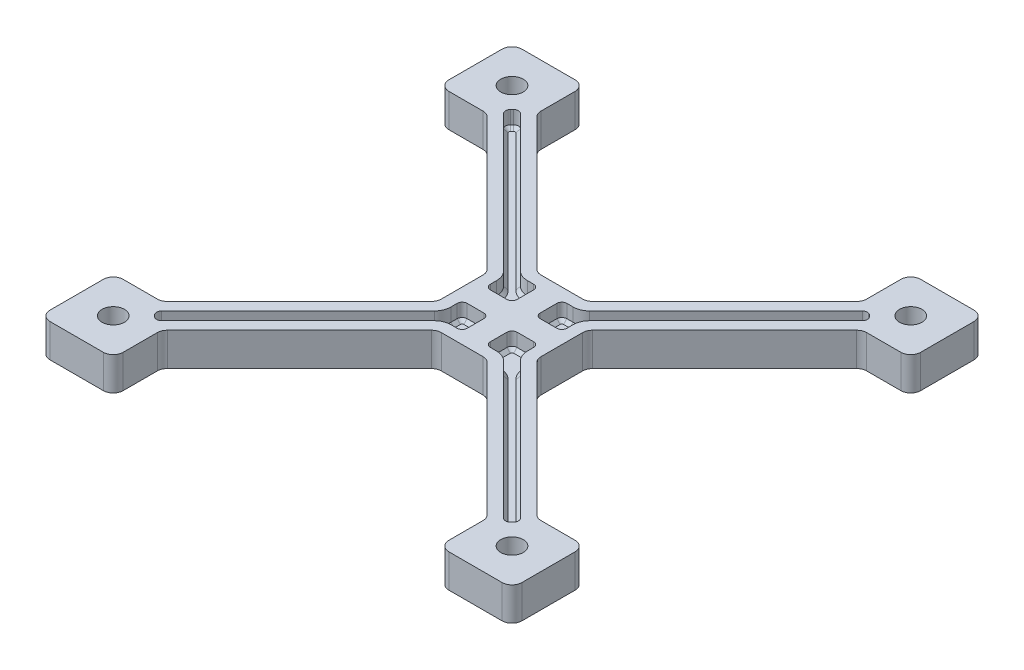
from build123d import *

# Parameters (mm, degrees)
SKETCH1_W               = 22
SKETCH1_H               = 22
BOSS_EXTRUDE1_DEPTH     = 10
F_1_4_CLEARANCE_HOLE1_D = 6.7564
CUT_EXTRUDE1_DEPTH      = 5
CHAMFER1_SIZE           = 1
FILLET1_R               = 3


with BuildPart() as part:
    # Sketch1 → Boss-Extrude1 (new body)
    with BuildSketch(Plane(origin=(0, 0, 0), x_dir=(1, 0, 0), z_dir=(0, 1, 0))):
        with Locations((15, 15)):
            Rectangle(SKETCH1_W, SKETCH1_H)
        Polygon((60, 60), (60, 67.5), (18.5, 26), (26, 26), (26, 18.5), (67.5, 60), align=None)
        Polygon((60, 75), (60, 90), (75, 90), (90, 90), (90, 60), (75, 60), (60, 60), align=None)
        Polygon((90, 60), (82.5, 60), (124, 18.5), (124, 26), (131.5, 26), (90, 67.5), align=None)
        with Locations((135, 15)):
            Rectangle(SKETCH1_W, SKETCH1_H)
        with Locations((135, 135)):
            Rectangle(SKETCH1_W, SKETCH1_H)
        Polygon((124, 131.5), (82.5, 90), (90, 90), (90, 82.5), (131.5, 124), (124, 124), align=None)
        Polygon((18.5, 124), (60, 82.5), (60, 90), (67.5, 90), (26, 131.5), (26, 124), align=None)
        with Locations((15, 135)):
            Rectangle(SKETCH1_W, SKETCH1_H)
    extrude(amount=-BOSS_EXTRUDE1_DEPTH)

    # 1/4 Clearance Hole1 (through all)
    with Locations(Plane(origin=(0, 0, 0), x_dir=(1, 0, 0), z_dir=(0, 1, 0))):
        with Locations((15, 15), (15, 135), (135, 135), (135, 15)):
            Hole(F_1_4_CLEARANCE_HOLE1_D / 2)

    # Sketch4 → Cut-Extrude1 (cut)
    with BuildSketch(Plane(origin=(0, 0, 0), x_dir=(1, 0, 0), z_dir=(0, 1, 0))):
        with BuildLine():
            Line((86.5, 70), (86.5, 68.121320344))
            ThreePointArc((86.5, 68.121320344), (86.880602337, 66.207903182), (87.964466094, 64.585786438))
            Line((87.964466094, 64.585786438), (128.98959236, 23.560660172))
            ThreePointArc((128.98959236, 23.560660172), (129.428932188, 22.5), (128.98959236, 21.439339828))
            Line((128.98959236, 21.439339828), (128.560660172, 21.01040764))
            ThreePointArc((128.560660172, 21.01040764), (127.5, 20.571067812), (126.439339828, 21.01040764))
            Line((126.439339828, 21.01040764), (85.414213562, 62.035533906))
            ThreePointArc((85.414213562, 62.035533906), (83.792096818, 63.119397663), (81.878679656, 63.5))
            Line((81.878679656, 63.5), (80, 63.5))
            ThreePointArc((80, 63.5), (78.939339828, 63.939339828), (78.5, 65))
            Line((78.5, 65), (78.5, 70))
            ThreePointArc((78.5, 70), (78.939339828, 71.060660172), (80, 71.5))
            Line((80, 71.5), (85, 71.5))
            ThreePointArc((85, 71.5), (86.060660172, 71.060660172), (86.5, 70))
        make_face()
        with BuildLine():
            Line((62.035533906, 64.585786438), (21.01040764, 23.560660172))
            ThreePointArc((21.01040764, 23.560660172), (20.571067812, 22.5), (21.01040764, 21.439339828))
            Line((21.01040764, 21.439339828), (21.439339828, 21.01040764))
            ThreePointArc((21.439339828, 21.01040764), (22.5, 20.571067812), (23.560660172, 21.01040764))
            Line((23.560660172, 21.01040764), (64.585786438, 62.035533906))
            ThreePointArc((64.585786438, 62.035533906), (66.207903182, 63.119397663), (68.121320344, 63.5))
            Line((68.121320344, 63.5), (70, 63.5))
            ThreePointArc((70, 63.5), (71.060660172, 63.939339828), (71.5, 65))
            Line((71.5, 65), (71.5, 70))
            ThreePointArc((71.5, 70), (71.060660172, 71.060660172), (70, 71.5))
            Line((70, 71.5), (65, 71.5))
            ThreePointArc((65, 71.5), (63.939339828, 71.060660172), (63.5, 70))
            Line((63.5, 70), (63.5, 68.121320344))
            ThreePointArc((63.5, 68.121320344), (63.119397663, 66.207903182), (62.035533906, 64.585786438))
        make_face()
        with BuildLine():
            Line((63.5, 80), (63.5, 81.878679656))
            ThreePointArc((63.5, 81.878679656), (63.119397663, 83.792096818), (62.035533906, 85.414213562))
            Line((62.035533906, 85.414213562), (21.01040764, 126.439339828))
            ThreePointArc((21.01040764, 126.439339828), (20.571067812, 127.5), (21.01040764, 128.560660172))
            Line((21.01040764, 128.560660172), (21.439339828, 128.98959236))
            ThreePointArc((21.439339828, 128.98959236), (22.5, 129.428932188), (23.560660172, 128.98959236))
            Line((23.560660172, 128.98959236), (64.585786438, 87.964466094))
            ThreePointArc((64.585786438, 87.964466094), (66.207903182, 86.880602337), (68.121320344, 86.5))
            Line((68.121320344, 86.5), (70, 86.5))
            ThreePointArc((70, 86.5), (71.060660172, 86.060660172), (71.5, 85))
            Line((71.5, 85), (71.5, 80))
            ThreePointArc((71.5, 80), (71.060660172, 78.939339828), (70, 78.5))
            Line((70, 78.5), (65, 78.5))
            ThreePointArc((65, 78.5), (63.939339828, 78.939339828), (63.5, 80))
        make_face()
        with BuildLine():
            Line((128.560660172, 128.98959236), (128.98959236, 128.560660172))
            ThreePointArc((128.98959236, 128.560660172), (129.428932188, 127.5), (128.98959236, 126.439339828))
            Line((128.98959236, 126.439339828), (87.964466094, 85.414213562))
            ThreePointArc((87.964466094, 85.414213562), (86.880602337, 83.792096818), (86.5, 81.878679656))
            Line((86.5, 81.878679656), (86.5, 80))
            ThreePointArc((86.5, 80), (86.060660172, 78.939339828), (85, 78.5))
            Line((85, 78.5), (80, 78.5))
            ThreePointArc((80, 78.5), (78.939339828, 78.939339828), (78.5, 80))
            Line((78.5, 80), (78.5, 85))
            ThreePointArc((78.5, 85), (78.939339828, 86.060660172), (80, 86.5))
            Line((80, 86.5), (81.878679656, 86.5))
            ThreePointArc((81.878679656, 86.5), (83.792096818, 86.880602337), (85.414213562, 87.964466094))
            Line((85.414213562, 87.964466094), (126.439339828, 128.98959236))
            ThreePointArc((126.439339828, 128.98959236), (127.5, 129.428932188), (128.560660172, 128.98959236))
        make_face()
    extrude(amount=-CUT_EXTRUDE1_DEPTH, mode=Mode.SUBTRACT)

    # Chamfer1
    chamfer1_edges = [part.edges().sort_by_distance(p)[0] for p in [
        (18.3782, -10, -135),
        (18.3782, -10, -15),
        (63.119397663, -5, -83.792096818),
        (41.522970773, -5, -105.926776695),
        (20.571067812, -5, -127.5),
        (21.224873734, -5, -128.775126266),
        (22.5, -5, -129.428932188),
        (44.073223305, -5, -108.477029227),
        (66.207903182, -5, -86.880602337),
        (69.060660172, -5, -86.5),
        (71.060660172, -5, -86.060660172),
        (71.5, -5, -82.5),
        (71.060660172, -5, -78.939339828),
        (67.5, -5, -78.5),
        (63.939339828, -5, -78.939339828),
        (63.5, -5, -80.939339828),
        (63.119397663, -5, -66.207903182),
        (63.5, -5, -69.060660172),
        (63.939339828, -5, -71.060660172),
        (67.5, -5, -71.5),
        (71.060660172, -5, -71.060660172),
        (71.5, -5, -67.5),
        (71.060660172, -5, -63.939339828),
        (69.060660172, -5, -63.5),
        (66.207903182, -5, -63.119397663),
        (44.073223305, -5, -41.522970773),
        (22.5, -5, -20.571067812),
        (21.224873734, -5, -21.224873734),
        (20.571067812, -5, -22.5),
        (41.522970773, -5, -44.073223305),
        (86.880602337, -5, -66.207903182),
        (108.477029227, -5, -44.073223305),
        (129.428932188, -5, -22.5),
        (128.775126266, -5, -21.224873734),
        (127.5, -5, -20.571067812),
        (105.926776695, -5, -41.522970773),
        (83.792096818, -5, -63.119397663),
        (80.939339828, -5, -63.5),
        (78.939339828, -5, -63.939339828),
        (78.5, -5, -67.5),
        (78.939339828, -5, -71.060660172),
        (82.5, -5, -71.5),
        (86.060660172, -5, -71.060660172),
        (86.5, -5, -69.060660172),
        (86.880602337, -5, -83.792096818),
        (86.5, -5, -80.939339828),
        (86.060660172, -5, -78.939339828),
        (82.5, -5, -78.5),
        (78.939339828, -5, -78.939339828),
        (78.5, -5, -82.5),
        (78.939339828, -5, -86.060660172),
        (80.939339828, -5, -86.5),
        (83.792096818, -5, -86.880602337),
        (105.926776695, -5, -108.477029227),
        (127.5, -5, -129.428932188),
        (128.775126266, -5, -128.775126266),
        (129.428932188, -5, -127.5),
        (108.477029227, -5, -105.926776695),
        (138.3782, -10, -15),
        (138.3782, -10, -135),
    ]]
    chamfer(chamfer1_edges, length=CHAMFER1_SIZE)

    # Fillet1
    fillet1_edges = [part.edges().sort_by_distance(p)[0] for p in [
        (90, -5, -67.5),
        (131.5, -5, -26),
        (146, -5, -26),
        (146, -5, -4),
        (124, -5, -4),
        (124, -5, -18.5),
        (82.5, -5, -60),
        (67.5, -5, -60),
        (26, -5, -18.5),
        (26, -5, -4),
        (4, -5, -4),
        (4, -5, -26),
        (18.5, -5, -26),
        (60, -5, -67.5),
        (60, -5, -82.5),
        (18.5, -5, -124),
        (4, -5, -124),
        (4, -5, -146),
        (26, -5, -146),
        (26, -5, -131.5),
        (67.5, -5, -90),
        (82.5, -5, -90),
        (124, -5, -131.5),
        (124, -5, -146),
        (146, -5, -146),
        (146, -5, -124),
        (131.5, -5, -124),
        (90, -5, -82.5),
    ]]
    fillet(fillet1_edges, radius=FILLET1_R)


solid = part.part
